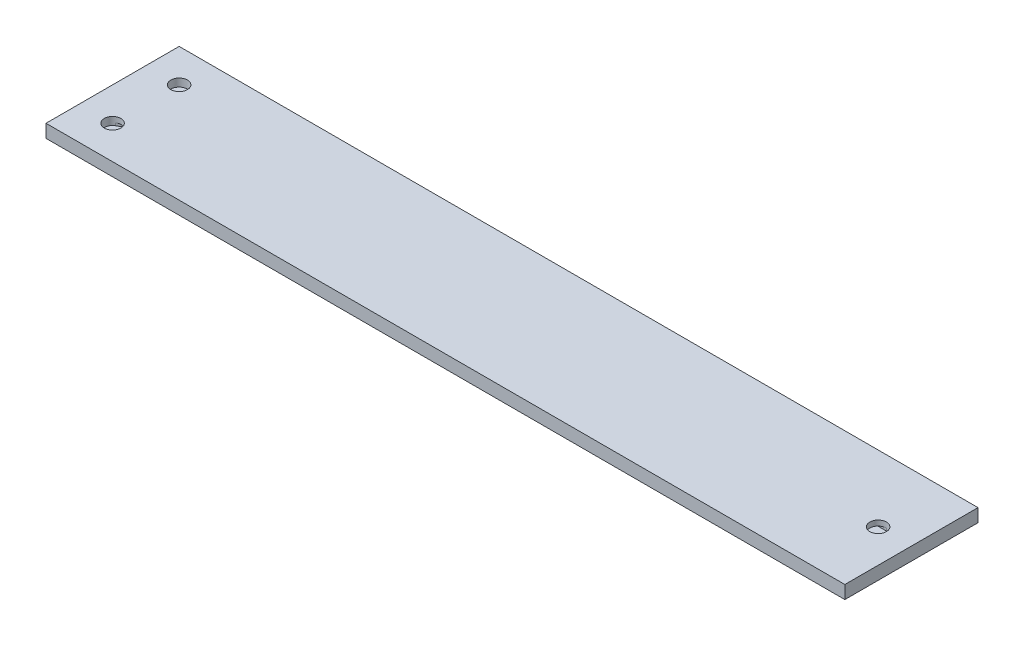
from build123d import *

# Parameters (mm, degrees)
BOSS_EXTRUDE1_DEPTH = 1
SKETCH5_W           = 152.4
SKETCH5_H           = 25.4
BOSS_EXTRUDE3_DEPTH = 0.5
CUT_EXTRUDE1_DEPTH  = 0.5
SKETCH7_W           = 1.5875
SKETCH7_H           = 1.5875
SKETCH7_W_2         = 3.175
CUT_EXTRUDE2_DEPTH  = 0.5
SKETCH8_W           = 152.4
SKETCH8_H           = 25.4
BOSS_EXTRUDE4_DEPTH = 1
CUT_EXTRUDE8_REACH  = 4.5
SKETCH9_R           = 1.5875


with BuildPart() as part:
    # Sketch1 → Boss-Extrude1 (new body)
    with BuildSketch(Plane(origin=(0, 0, 0), x_dir=(1, 0, 0), z_dir=(0, 1, 0))):
        Polygon((-44.45, -12.7), (31.75, -12.7), (57.15, -12.7), (57.15, 12.7), (31.75, 12.7), (-44.45, 12.7), (-69.85, 12.7), (-95.25, 12.7), (-95.25, -12.7), (-69.85, -12.7), align=None)
    extrude(amount=BOSS_EXTRUDE1_DEPTH)

    # Sketch5 → Boss-Extrude3 (add)
    with BuildSketch(Plane(origin=(0, 1, 0), x_dir=(1, 0, 0), z_dir=(0, 1, 0))):
        with Locations((-19.05, 0)):
            Rectangle(SKETCH5_W, SKETCH5_H)
        with BuildLine():
            ThreePointArc((-31.75, -1.5875), (-33.3375, 0), (-31.75, 1.5875))
            Line((-31.75, 1.5875), (-25.825369343, 1.5875))
            Line((-25.825369343, 1.5875), (-18.861401581, 5.608148662))
            ThreePointArc((-18.861401581, 5.608148662), (-18.478526815, 5.766740583), (-18.067651581, 5.820833333))
            Line((-18.067651581, 5.820833333), (-12.143020924, 5.820833333))
            Line((-12.143020924, 5.820833333), (-8.845227372, 7.724815329))
            ThreePointArc((-8.845227372, 7.724815329), (-8.462352606, 7.883407249), (-8.051477372, 7.9375))
            Line((-8.051477372, 7.9375), (-1.701477372, 7.9375))
            ThreePointArc((-1.701477372, 7.9375), (-0.113977372, 6.35), (-1.701477372, 4.7625))
            Line((-1.701477372, 4.7625), (-7.626108029, 4.7625))
            Line((-7.626108029, 4.7625), (-8.542651581, 4.233333333))
            Line((-8.542651581, 4.233333333), (-7.626108029, 3.704166667))
            Line((-7.626108029, 3.704166667), (-1.701477372, 3.704166667))
            ThreePointArc((-1.701477372, 3.704166667), (-0.113977372, 2.116666667), (-1.701477372, 0.529166667))
            Line((-1.701477372, 0.529166667), (-8.051477372, 0.529166667))
            ThreePointArc((-8.051477372, 0.529166667), (-8.462352606, 0.583259417), (-8.845227372, 0.741851338))
            Line((-8.845227372, 0.741851338), (-12.143020924, 2.645833333))
            Line((-12.143020924, 2.645833333), (-17.642282238, 2.645833333))
            Line((-17.642282238, 2.645833333), (-22.225, 0))
            Line((-22.225, 0), (-17.642282238, -2.645833333))
            Line((-17.642282238, -2.645833333), (-12.143020924, -2.645833333))
            Line((-12.143020924, -2.645833333), (-8.845227372, -0.741851338))
            ThreePointArc((-8.845227372, -0.741851338), (-8.462352606, -0.583259417), (-8.051477372, -0.529166667))
            Line((-8.051477372, -0.529166667), (-1.701477372, -0.529166667))
            ThreePointArc((-1.701477372, -0.529166667), (-0.113977372, -2.116666667), (-1.701477372, -3.704166667))
            Line((-1.701477372, -3.704166667), (-7.626108029, -3.704166667))
            Line((-7.626108029, -3.704166667), (-8.542651581, -4.233333333))
            Line((-8.542651581, -4.233333333), (-7.626108029, -4.7625))
            Line((-7.626108029, -4.7625), (-1.701477372, -4.7625))
            ThreePointArc((-1.701477372, -4.7625), (-0.113977372, -6.35), (-1.701477372, -7.9375))
            Line((-1.701477372, -7.9375), (-8.051477372, -7.9375))
            ThreePointArc((-8.051477372, -7.9375), (-8.462352606, -7.883407249), (-8.845227372, -7.724815329))
            Line((-8.845227372, -7.724815329), (-12.143020924, -5.820833333))
            Line((-12.143020924, -5.820833333), (-18.067651581, -5.820833333))
            ThreePointArc((-18.067651581, -5.820833333), (-18.478526815, -5.766740583), (-18.861401581, -5.608148662))
            Line((-18.861401581, -5.608148662), (-25.825369343, -1.5875))
            Line((-25.825369343, -1.5875), (-31.75, -1.5875))
        make_face(mode=Mode.SUBTRACT)
    extrude(amount=BOSS_EXTRUDE3_DEPTH)

    # Sketch6 → Cut-Extrude1 (cut)
    with BuildSketch(Plane(origin=(0, 1.5, 0), x_dir=(1, 0, 0), z_dir=(0, 1, 0))):
        with BuildLine():
            Line((-1.701477372, -7.9375), (10.329619478, -7.9375))
            ThreePointArc((10.329619478, -7.9375), (10.665963649, -7.919634397), (10.998522628, -7.866238645))
            Line((10.998522628, -7.866238645), (10.998522628, 7.866238645))
            ThreePointArc((10.998522628, 7.866238645), (10.665963649, 7.919634397), (10.329619478, 7.9375))
            Line((10.329619478, 7.9375), (-1.701477372, 7.9375))
            ThreePointArc((-1.701477372, 7.9375), (-0.113977372, 6.35), (-1.701477372, 4.7625))
            Line((-1.701477372, 4.7625), (-1.701477372, 3.704166667))
            ThreePointArc((-1.701477372, 3.704166667), (-0.113977372, 2.116666667), (-1.701477372, 0.529166667))
            Line((-1.701477372, 0.529166667), (-1.701477372, -0.529166667))
            ThreePointArc((-1.701477372, -0.529166667), (-0.113977372, -2.116666667), (-1.701477372, -3.704166667))
            Line((-1.701477372, -3.704166667), (-1.701477372, -4.7625))
            ThreePointArc((-1.701477372, -4.7625), (-0.113977372, -6.35), (-1.701477372, -7.9375))
        make_face()
        with BuildLine():
            Line((10.998522628, 7.866238645), (10.998522628, -7.866238645))
            ThreePointArc((10.998522628, -7.866238645), (11.309590864, -7.782480312), (11.610570405, -7.667631619))
            Line((11.610570405, -7.667631619), (25.4, -1.5875))
            ThreePointArc((25.4, -1.5875), (23.8125, 0), (25.4, 1.5875))
            Line((25.4, 1.5875), (11.610570405, 7.667631619))
            ThreePointArc((11.610570405, 7.667631619), (11.309590864, 7.782480312), (10.998522628, 7.866238645))
        make_face()
        with BuildLine():
            ThreePointArc((25.4, 1.5875), (23.8125, 0), (25.4, -1.5875))
            Line((25.4, -1.5875), (25.4, 1.5875))
        make_face()
        with BuildLine():
            Line((25.4, 1.5875), (25.4, -1.5875))
            ThreePointArc((25.4, -1.5875), (26.522532015, -1.122532015), (26.9875, 0))
            ThreePointArc((26.9875, 0), (26.522532015, 1.122532015), (25.4, 1.5875))
        make_face()
        with BuildLine():
            ThreePointArc((26.9875, 0), (26.522532015, -1.122532015), (25.4, -1.5875))
            Line((25.4, -1.5875), (50.8, -1.5875))
            ThreePointArc((50.8, -1.5875), (52.3875, 0), (50.8, 1.5875))
            Line((50.8, 1.5875), (25.4, 1.5875))
            ThreePointArc((25.4, 1.5875), (26.522532015, 1.122532015), (26.9875, 0))
        make_face()
    extrude(amount=-CUT_EXTRUDE1_DEPTH, mode=Mode.SUBTRACT)

    # Sketch7 → Cut-Extrude2 (cut)
    with BuildSketch(Plane(origin=(0, 1.5, 0), x_dir=(1, 0, 0), z_dir=(0, 1, 0))):
        with Locations((-32.54375, 5.55625)):
            Rectangle(SKETCH7_W, SKETCH7_H)
        with BuildLine():
            ThreePointArc((-30.1625, 6.35), (-30.627467985, 5.227467985), (-31.75, 4.7625))
            Line((-31.75, 4.7625), (-33.3375, 4.7625))
            Line((-33.3375, 4.7625), (-33.3375, 0))
            ThreePointArc((-33.3375, 0), (-31.75, -1.5875), (-30.1625, 0))
            Line((-30.1625, 0), (-30.1625, 6.35))
        make_face()
        with BuildLine():
            Line((-31.75, 6.35), (-31.75, 4.7625))
            ThreePointArc((-31.75, 4.7625), (-30.627467985, 5.227467985), (-30.1625, 6.35))
            ThreePointArc((-30.1625, 6.35), (-30.627467985, 7.472532015), (-31.75, 7.9375))
            ThreePointArc((-31.75, 7.9375), (-32.872532015, 7.472532015), (-33.3375, 6.35))
            Line((-33.3375, 6.35), (-31.75, 6.35))
        make_face()
        with Locations((-34.925, 5.55625)):
            Rectangle(SKETCH7_W_2, SKETCH7_H)
        with BuildLine():
            Line((-36.5125, 6.35), (-33.3375, 6.35))
            ThreePointArc((-33.3375, 6.35), (-32.872532015, 7.472532015), (-31.75, 7.9375))
            Line((-31.75, 7.9375), (-38.1, 7.9375))
            ThreePointArc((-38.1, 7.9375), (-36.977467985, 7.472532015), (-36.5125, 6.35))
        make_face()
        with Locations((-37.30625, 5.55625)):
            Rectangle(SKETCH7_W, SKETCH7_H)
        with BuildLine():
            Line((-36.5125, -6.35), (-36.5125, 4.7625))
            Line((-36.5125, 4.7625), (-38.1, 4.7625))
            Line((-38.1, 4.7625), (-38.1, -4.7625))
            ThreePointArc((-38.1, -4.7625), (-36.977467985, -5.227467985), (-36.5125, -6.35))
        make_face()
        with BuildLine():
            Line((-38.1, 6.35), (-36.5125, 6.35))
            ThreePointArc((-36.5125, 6.35), (-36.977467985, 7.472532015), (-38.1, 7.9375))
            ThreePointArc((-38.1, 7.9375), (-39.222532015, 7.472532015), (-39.6875, 6.35))
            ThreePointArc((-39.6875, 6.35), (-39.222532015, 5.227467985), (-38.1, 4.7625))
            Line((-38.1, 4.7625), (-38.1, 6.35))
        make_face()
        with BuildLine():
            ThreePointArc((-38.1, -7.9375), (-36.977467985, -7.472532015), (-36.5125, -6.35))
            ThreePointArc((-36.5125, -6.35), (-36.977467985, -5.227467985), (-38.1, -4.7625))
            Line((-38.1, -4.7625), (-38.1, -6.35))
            Line((-38.1, -6.35), (-39.6875, -6.35))
            ThreePointArc((-39.6875, -6.35), (-39.222532015, -7.472532015), (-38.1, -7.9375))
        make_face()
        with BuildLine():
            Line((-38.1, -4.7625), (-38.1, 4.7625))
            ThreePointArc((-38.1, 4.7625), (-39.222532015, 5.227467985), (-39.6875, 6.35))
            Line((-39.6875, 6.35), (-39.6875, -4.7625))
            Line((-39.6875, -4.7625), (-38.1, -4.7625))
        make_face()
        with BuildLine():
            Line((-44.45, -7.9375), (-38.1, -7.9375))
            ThreePointArc((-38.1, -7.9375), (-39.222532015, -7.472532015), (-39.6875, -6.35))
            Line((-39.6875, -6.35), (-42.8625, -6.35))
            ThreePointArc((-42.8625, -6.35), (-43.327467985, -7.472532015), (-44.45, -7.9375))
        make_face()
        with Locations((-38.89375, -5.55625)):
            Rectangle(SKETCH7_W, SKETCH7_H)
        with BuildLine():
            ThreePointArc((-46.0375, -6.35), (-45.572532015, -7.472532015), (-44.45, -7.9375))
            ThreePointArc((-44.45, -7.9375), (-43.327467985, -7.472532015), (-42.8625, -6.35))
            Line((-42.8625, -6.35), (-44.45, -6.35))
            Line((-44.45, -6.35), (-44.45, -4.7625))
            ThreePointArc((-44.45, -4.7625), (-45.572532015, -5.227467985), (-46.0375, -6.35))
        make_face()
        with Locations((-41.275, -5.55625)):
            Rectangle(SKETCH7_W_2, SKETCH7_H)
        with BuildLine():
            Line((-46.0375, 0), (-46.0375, -6.35))
            ThreePointArc((-46.0375, -6.35), (-45.572532015, -5.227467985), (-44.45, -4.7625))
            Line((-44.45, -4.7625), (-44.45, -1.5875))
            ThreePointArc((-44.45, -1.5875), (-45.572532015, -1.122532015), (-46.0375, 0))
        make_face()
        with Locations((-43.65625, -5.55625)):
            Rectangle(SKETCH7_W, SKETCH7_H)
        with BuildLine():
            Line((-44.45, -4.7625), (-42.8625, -4.7625))
            Line((-42.8625, -4.7625), (-42.8625, 0))
            ThreePointArc((-42.8625, 0), (-43.327467985, -1.122532015), (-44.45, -1.5875))
            Line((-44.45, -1.5875), (-44.45, -4.7625))
        make_face()
        with BuildLine():
            Line((-46.0375, 4.7625), (-46.0375, 0))
            ThreePointArc((-46.0375, 0), (-44.45, 1.5875), (-42.8625, 0))
            Line((-42.8625, 0), (-42.8625, 6.35))
            ThreePointArc((-42.8625, 6.35), (-43.327467985, 5.227467985), (-44.45, 4.7625))
            Line((-44.45, 4.7625), (-46.0375, 4.7625))
        make_face()
        with BuildLine():
            ThreePointArc((-42.8625, 0), (-44.45, 1.5875), (-46.0375, 0))
            ThreePointArc((-46.0375, 0), (-45.572532015, -1.122532015), (-44.45, -1.5875))
            ThreePointArc((-44.45, -1.5875), (-43.327467985, -1.122532015), (-42.8625, 0))
        make_face()
        with BuildLine():
            Line((-46.0375, 6.35), (-46.0375, 4.7625))
            Line((-46.0375, 4.7625), (-44.45, 4.7625))
            ThreePointArc((-44.45, 4.7625), (-43.327467985, 5.227467985), (-42.8625, 6.35))
            ThreePointArc((-42.8625, 6.35), (-43.327467985, 7.472532015), (-44.45, 7.9375))
            ThreePointArc((-44.45, 7.9375), (-45.572532015, 7.472532015), (-46.0375, 6.35))
        make_face()
        with BuildLine():
            Line((-49.2125, 4.7625), (-46.0375, 4.7625))
            Line((-46.0375, 4.7625), (-46.0375, 6.35))
            ThreePointArc((-46.0375, 6.35), (-45.572532015, 7.472532015), (-44.45, 7.9375))
            Line((-44.45, 7.9375), (-50.8, 7.9375))
            ThreePointArc((-50.8, 7.9375), (-49.677467985, 7.472532015), (-49.2125, 6.35))
            Line((-49.2125, 6.35), (-49.2125, 4.7625))
        make_face()
        with BuildLine():
            Line((-50.8, 4.7625), (-49.2125, 4.7625))
            Line((-49.2125, 4.7625), (-49.2125, 6.35))
            ThreePointArc((-49.2125, 6.35), (-49.677467985, 7.472532015), (-50.8, 7.9375))
            ThreePointArc((-50.8, 7.9375), (-51.922532015, 7.472532015), (-52.3875, 6.35))
            ThreePointArc((-52.3875, 6.35), (-51.922532015, 5.227467985), (-50.8, 4.7625))
        make_face()
        with BuildLine():
            Line((-49.2125, -6.35), (-49.2125, 4.7625))
            Line((-49.2125, 4.7625), (-50.8, 4.7625))
            ThreePointArc((-50.8, 4.7625), (-51.922532015, 5.227467985), (-52.3875, 6.35))
            Line((-52.3875, 6.35), (-52.3875, -4.7625))
            Line((-52.3875, -4.7625), (-50.8, -4.7625))
            ThreePointArc((-50.8, -4.7625), (-49.677467985, -5.227467985), (-49.2125, -6.35))
        make_face()
        with BuildLine():
            ThreePointArc((-50.8, -7.9375), (-49.677467985, -7.472532015), (-49.2125, -6.35))
            ThreePointArc((-49.2125, -6.35), (-49.677467985, -5.227467985), (-50.8, -4.7625))
            Line((-50.8, -4.7625), (-52.3875, -4.7625))
            Line((-52.3875, -4.7625), (-52.3875, -6.35))
            ThreePointArc((-52.3875, -6.35), (-51.922532015, -7.472532015), (-50.8, -7.9375))
        make_face()
        with BuildLine():
            Line((-57.15, -7.9375), (-50.8, -7.9375))
            ThreePointArc((-50.8, -7.9375), (-51.922532015, -7.472532015), (-52.3875, -6.35))
            Line((-52.3875, -6.35), (-52.3875, -4.7625))
            Line((-52.3875, -4.7625), (-55.5625, -4.7625))
            Line((-55.5625, -4.7625), (-55.5625, -6.35))
            ThreePointArc((-55.5625, -6.35), (-56.027467985, -7.472532015), (-57.15, -7.9375))
        make_face()
        with BuildLine():
            ThreePointArc((-58.7375, -6.35), (-58.272532015, -7.472532015), (-57.15, -7.9375))
            ThreePointArc((-57.15, -7.9375), (-56.027467985, -7.472532015), (-55.5625, -6.35))
            Line((-55.5625, -6.35), (-55.5625, -4.7625))
            Line((-55.5625, -4.7625), (-57.15, -4.7625))
            ThreePointArc((-57.15, -4.7625), (-58.272532015, -5.227467985), (-58.7375, -6.35))
        make_face()
        with BuildLine():
            Line((-58.7375, 0), (-58.7375, -6.35))
            ThreePointArc((-58.7375, -6.35), (-58.272532015, -5.227467985), (-57.15, -4.7625))
            Line((-57.15, -4.7625), (-55.5625, -4.7625))
            Line((-55.5625, -4.7625), (-55.5625, 0))
            ThreePointArc((-55.5625, 0), (-57.15, -1.5875), (-58.7375, 0))
        make_face()
        with BuildLine():
            Line((-58.7375, 4.7625), (-58.7375, 0))
            ThreePointArc((-58.7375, 0), (-57.15, 1.5875), (-55.5625, 0))
            Line((-55.5625, 0), (-55.5625, 6.35))
            ThreePointArc((-55.5625, 6.35), (-56.027467985, 5.227467985), (-57.15, 4.7625))
            Line((-57.15, 4.7625), (-58.7375, 4.7625))
        make_face()
        with BuildLine():
            ThreePointArc((-55.5625, 0), (-57.15, 1.5875), (-58.7375, 0))
            ThreePointArc((-58.7375, 0), (-57.15, -1.5875), (-55.5625, 0))
        make_face()
        with BuildLine():
            Line((-58.7375, 6.35), (-58.7375, 4.7625))
            Line((-58.7375, 4.7625), (-57.15, 4.7625))
            ThreePointArc((-57.15, 4.7625), (-56.027467985, 5.227467985), (-55.5625, 6.35))
            ThreePointArc((-55.5625, 6.35), (-56.027467985, 7.472532015), (-57.15, 7.9375))
            ThreePointArc((-57.15, 7.9375), (-58.272532015, 7.472532015), (-58.7375, 6.35))
        make_face()
        with BuildLine():
            Line((-61.9125, 4.7625), (-58.7375, 4.7625))
            Line((-58.7375, 4.7625), (-58.7375, 6.35))
            ThreePointArc((-58.7375, 6.35), (-58.272532015, 7.472532015), (-57.15, 7.9375))
            Line((-57.15, 7.9375), (-63.5, 7.9375))
            ThreePointArc((-63.5, 7.9375), (-62.377467985, 7.472532015), (-61.9125, 6.35))
            Line((-61.9125, 6.35), (-61.9125, 4.7625))
        make_face()
        with BuildLine():
            Line((-63.5, 4.7625), (-61.9125, 4.7625))
            Line((-61.9125, 4.7625), (-61.9125, 6.35))
            ThreePointArc((-61.9125, 6.35), (-62.377467985, 7.472532015), (-63.5, 7.9375))
            ThreePointArc((-63.5, 7.9375), (-64.622532015, 7.472532015), (-65.0875, 6.35))
            ThreePointArc((-65.0875, 6.35), (-64.622532015, 5.227467985), (-63.5, 4.7625))
        make_face()
        with BuildLine():
            Line((-61.9125, -6.35), (-61.9125, 4.7625))
            Line((-61.9125, 4.7625), (-63.5, 4.7625))
            ThreePointArc((-63.5, 4.7625), (-64.622532015, 5.227467985), (-65.0875, 6.35))
            Line((-65.0875, 6.35), (-65.0875, -4.7625))
            Line((-65.0875, -4.7625), (-63.5, -4.7625))
            ThreePointArc((-63.5, -4.7625), (-62.377467985, -5.227467985), (-61.9125, -6.35))
        make_face()
        with BuildLine():
            ThreePointArc((-63.5, -7.9375), (-62.377467985, -7.472532015), (-61.9125, -6.35))
            ThreePointArc((-61.9125, -6.35), (-62.377467985, -5.227467985), (-63.5, -4.7625))
            Line((-63.5, -4.7625), (-65.0875, -4.7625))
            Line((-65.0875, -4.7625), (-65.0875, -6.35))
            ThreePointArc((-65.0875, -6.35), (-64.622532015, -7.472532015), (-63.5, -7.9375))
        make_face()
        with BuildLine():
            Line((-69.85, -7.9375), (-63.5, -7.9375))
            ThreePointArc((-63.5, -7.9375), (-64.622532015, -7.472532015), (-65.0875, -6.35))
            Line((-65.0875, -6.35), (-65.0875, -4.7625))
            Line((-65.0875, -4.7625), (-68.2625, -4.7625))
            Line((-68.2625, -4.7625), (-68.2625, -6.35))
            ThreePointArc((-68.2625, -6.35), (-68.727467985, -7.472532015), (-69.85, -7.9375))
        make_face()
        with BuildLine():
            ThreePointArc((-71.4375, -6.35), (-70.972532015, -7.472532015), (-69.85, -7.9375))
            ThreePointArc((-69.85, -7.9375), (-68.727467985, -7.472532015), (-68.2625, -6.35))
            Line((-68.2625, -6.35), (-68.2625, -4.7625))
            Line((-68.2625, -4.7625), (-69.85, -4.7625))
            ThreePointArc((-69.85, -4.7625), (-70.972532015, -5.227467985), (-71.4375, -6.35))
        make_face()
        with BuildLine():
            Line((-71.4375, -1.5875), (-71.4375, -6.35))
            ThreePointArc((-71.4375, -6.35), (-70.972532015, -5.227467985), (-69.85, -4.7625))
            Line((-69.85, -4.7625), (-68.2625, -4.7625))
            Line((-68.2625, -4.7625), (-68.2625, 0))
            ThreePointArc((-68.2625, 0), (-68.727467985, -1.122532015), (-69.85, -1.5875))
            Line((-69.85, -1.5875), (-71.4375, -1.5875))
        make_face()
        with BuildLine():
            Line((-77.476108029, -1.5875), (-71.4375, -1.5875))
            Line((-71.4375, -1.5875), (-71.4375, 0))
            ThreePointArc((-71.4375, 0), (-70.972532015, 1.122532015), (-69.85, 1.5875))
            Line((-69.85, 1.5875), (-77.476108029, 1.5875))
            Line((-77.476108029, 1.5875), (-77.107727372, 1.374815329))
            ThreePointArc((-77.107727372, 1.374815329), (-76.313977372, 0), (-77.107727372, -1.374815329))
            Line((-77.107727372, -1.374815329), (-77.476108029, -1.5875))
        make_face()
        with BuildLine():
            Line((-71.4375, 0), (-71.4375, -1.5875))
            Line((-71.4375, -1.5875), (-69.85, -1.5875))
            ThreePointArc((-69.85, -1.5875), (-68.727467985, -1.122532015), (-68.2625, 0))
            ThreePointArc((-68.2625, 0), (-68.727467985, 1.122532015), (-69.85, 1.5875))
            ThreePointArc((-69.85, 1.5875), (-70.972532015, 1.122532015), (-71.4375, 0))
        make_face()
        with BuildLine():
            Line((-88.10625, -7.724815329), (-77.476108029, -1.5875))
            Line((-77.476108029, -1.5875), (-77.901477372, -1.5875))
            ThreePointArc((-77.901477372, -1.5875), (-78.312352606, -1.533407249), (-78.695227372, -1.374815329))
            Line((-78.695227372, -1.374815329), (-81.076477372, 0))
            Line((-81.076477372, 0), (-89.69375, -4.975184671))
            ThreePointArc((-89.69375, -4.975184671), (-90.274815329, -7.14375), (-88.10625, -7.724815329))
        make_face()
        with BuildLine():
            Line((-77.901477372, -1.5875), (-77.476108029, -1.5875))
            Line((-77.476108029, -1.5875), (-77.107727372, -1.374815329))
            ThreePointArc((-77.107727372, -1.374815329), (-77.490602138, -1.533407249), (-77.901477372, -1.5875))
        make_face()
        with BuildLine():
            ThreePointArc((-78.695227372, -1.374815329), (-78.312352606, -1.533407249), (-77.901477372, -1.5875))
            ThreePointArc((-77.901477372, -1.5875), (-77.490602138, -1.533407249), (-77.107727372, -1.374815329))
            ThreePointArc((-77.107727372, -1.374815329), (-76.313977372, 0), (-77.107727372, 1.374815329))
            ThreePointArc((-77.107727372, 1.374815329), (-77.490602138, 1.533407249), (-77.901477372, 1.5875))
            ThreePointArc((-77.901477372, 1.5875), (-78.312352606, 1.533407249), (-78.695227372, 1.374815329))
            ThreePointArc((-78.695227372, 1.374815329), (-79.488977372, 0), (-78.695227372, -1.374815329))
        make_face()
        with BuildLine():
            Line((-77.107727372, 1.374815329), (-77.476108029, 1.5875))
            Line((-77.476108029, 1.5875), (-77.901477372, 1.5875))
            ThreePointArc((-77.901477372, 1.5875), (-77.490602138, 1.533407249), (-77.107727372, 1.374815329))
        make_face()
        with BuildLine():
            Line((-77.901477372, 1.5875), (-77.476108029, 1.5875))
            Line((-77.476108029, 1.5875), (-88.10625, 7.724815329))
            ThreePointArc((-88.10625, 7.724815329), (-90.274815329, 7.14375), (-89.69375, 4.975184671))
            Line((-89.69375, 4.975184671), (-81.076477372, 0))
            Line((-81.076477372, 0), (-78.695227372, 1.374815329))
            ThreePointArc((-78.695227372, 1.374815329), (-78.312352606, 1.533407249), (-77.901477372, 1.5875))
        make_face()
        with BuildLine():
            Line((-81.076477372, 0), (-78.695227372, -1.374815329))
            ThreePointArc((-78.695227372, -1.374815329), (-79.488977372, 0), (-78.695227372, 1.374815329))
            Line((-78.695227372, 1.374815329), (-81.076477372, 0))
        make_face()
    extrude(amount=-CUT_EXTRUDE2_DEPTH, mode=Mode.SUBTRACT)

    # Sketch8 → Boss-Extrude4 (add)
    with BuildSketch(Plane(origin=(0, 1.5, 0), x_dir=(1, 0, 0), z_dir=(0, 1, 0))):
        with Locations((-19.05, 0)):
            Rectangle(SKETCH8_W, SKETCH8_H)
    extrude(amount=BOSS_EXTRUDE4_DEPTH)

    # Sketch9 → Cut-Extrude8 (cut, up to next)
    with BuildSketch(Plane(origin=(0, 2.5, 0), x_dir=(1, 0, 0), z_dir=(0, 1, 0)), mode=Mode.PRIVATE) as cut_extrude8_sk1:
        with Locations((-88.9, 6.35)):
            Circle(SKETCH9_R)
    cut_extrude8_tool1 = extrude(cut_extrude8_sk1.sketch, amount=-CUT_EXTRUDE8_REACH, mode=Mode.PRIVATE) & part.part
    add(cut_extrude8_tool1.solids().sort_by_distance((-88.9, 2.5, -6.35))[0], mode=Mode.SUBTRACT)
    # Sketch9 → Cut-Extrude8 (cut, up to next)
    with BuildSketch(Plane(origin=(0, 2.5, 0), x_dir=(1, 0, 0), z_dir=(0, 1, 0)), mode=Mode.PRIVATE) as cut_extrude8_sk2:
        with Locations((-88.9, -6.35)):
            Circle(SKETCH9_R)
    cut_extrude8_tool2 = extrude(cut_extrude8_sk2.sketch, amount=-CUT_EXTRUDE8_REACH, mode=Mode.PRIVATE) & part.part
    add(cut_extrude8_tool2.solids().sort_by_distance((-88.9, 2.5, 6.35))[0], mode=Mode.SUBTRACT)
    # Sketch9 → Cut-Extrude8 (cut, up to next)
    with BuildSketch(Plane(origin=(0, 2.5, 0), x_dir=(1, 0, 0), z_dir=(0, 1, 0)), mode=Mode.PRIVATE) as cut_extrude8_sk3:
        with Locations((50.8, 0)):
            Circle(SKETCH9_R)
    cut_extrude8_tool3 = extrude(cut_extrude8_sk3.sketch, amount=-CUT_EXTRUDE8_REACH, mode=Mode.PRIVATE) & part.part
    add(cut_extrude8_tool3.solids().sort_by_distance((50.8, 2.5, 0))[0], mode=Mode.SUBTRACT)


solid = part.part
